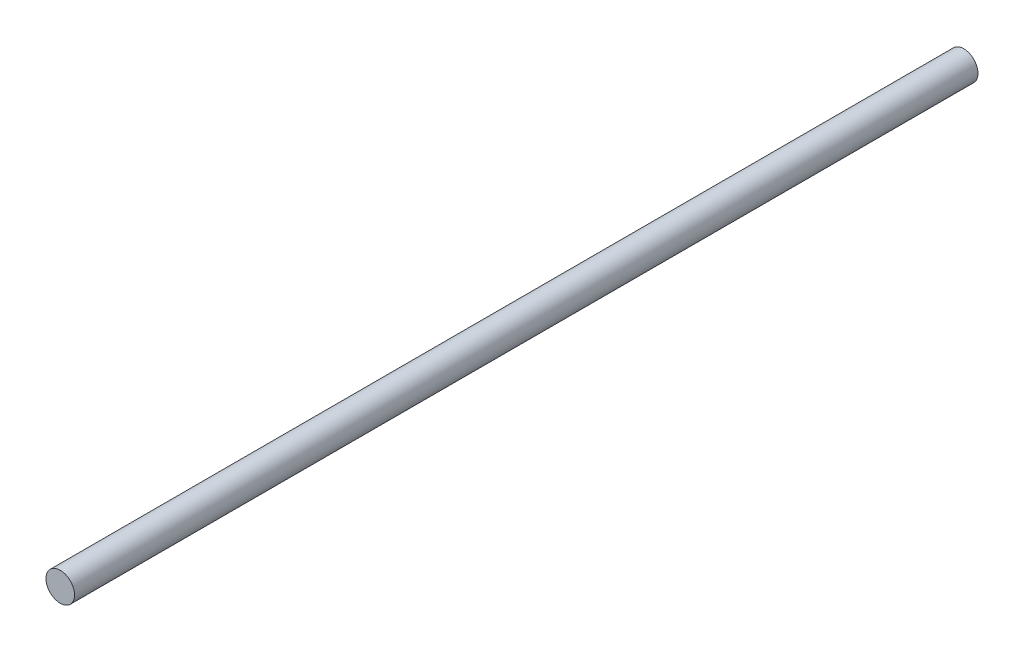
from build123d import *

# Parameters (mm, degrees)
SKETCH1_R           = 3.7970867
BOSS_EXTRUDE1_DEPTH = 240


with BuildPart() as part:
    # Sketch1 → Boss-Extrude1 (new body)
    with BuildSketch(Plane.XY):
        with Locations((-10.016557459, -10.016557459)):
            Circle(SKETCH1_R)
    extrude(amount=BOSS_EXTRUDE1_DEPTH)


solid = part.part
